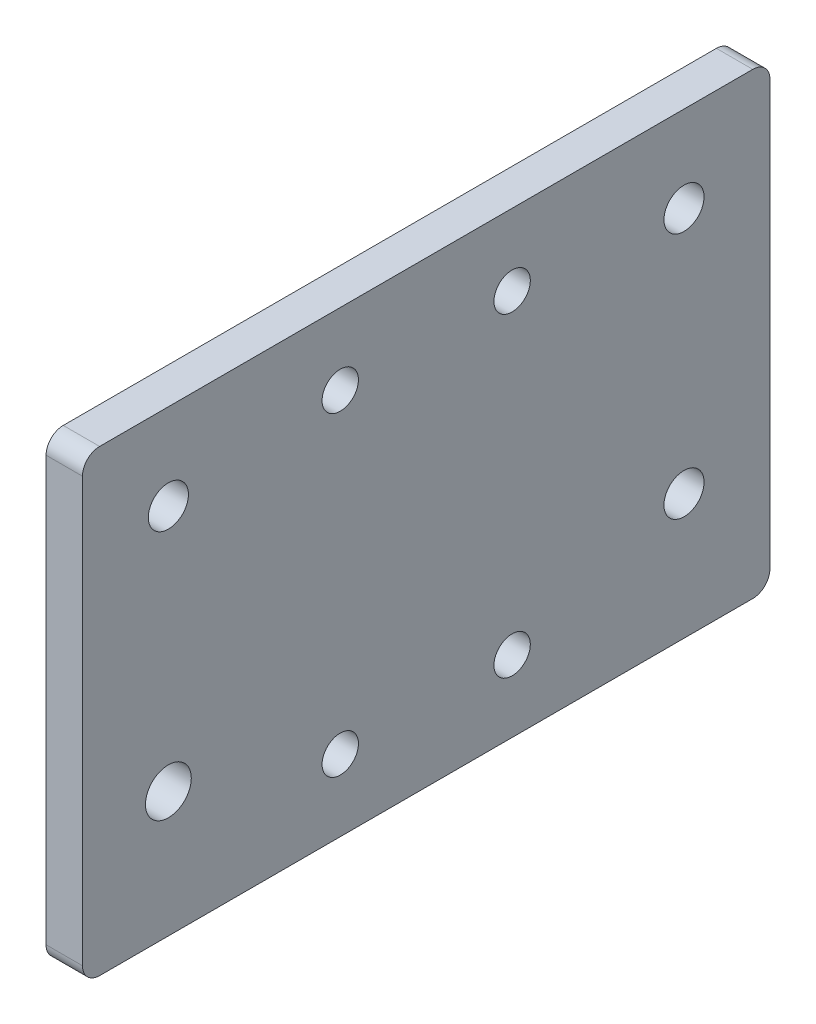
from build123d import *

# Parameters (mm, degrees)
SKETCH1_W           = 120
SKETCH1_H           = 80
SKETCH1_R           = 3.5
SKETCH1_R_2         = 4
BOSS_EXTRUDE1_DEPTH = 6.35
FILLET1_R           = 3
SKETCH2_R           = 3.175
CUT_EXTRUDE1_DEPTH  = 10


with BuildPart() as part:
    # Sketch1 → Boss-Extrude1 (new body)
    with BuildSketch(Plane(origin=(0, 0, 0), x_dir=(0, 0, -1), z_dir=(1, 0, 0))):
        Rectangle(SKETCH1_W, SKETCH1_H)
        with Locations((45, 25)):
            Circle(SKETCH1_R, mode=Mode.SUBTRACT)
        with Locations((-45, 25)):
            Circle(SKETCH1_R, mode=Mode.SUBTRACT)
        with Locations((-45, -18.13)):
            Circle(SKETCH1_R_2, mode=Mode.SUBTRACT)
        with Locations((45, -18.13)):
            Circle(SKETCH1_R, mode=Mode.SUBTRACT)
    extrude(amount=BOSS_EXTRUDE1_DEPTH)

    # Fillet1
    fillet1_edges = [part.edges().sort_by_distance(p)[0] for p in [
        (3.175, -40, -60),
        (3.175, -40, 60),
        (3.175, 40, 60),
        (3.175, 40, -60),
    ]]
    fillet(fillet1_edges, radius=FILLET1_R)

    # Sketch2 → Cut-Extrude1 (cut)
    with BuildSketch(Plane(origin=(6.35, 0, 0), x_dir=(0, 0, -1), z_dir=(1, 0, 0))):
        with Locations((-15, 27.5)):
            Circle(SKETCH2_R)
        with Locations((15, 27.5)):
            Circle(SKETCH2_R)
        with Locations((15, -27.5)):
            Circle(SKETCH2_R)
        with Locations((-15, -27.5)):
            Circle(SKETCH2_R)
    extrude(amount=-CUT_EXTRUDE1_DEPTH, mode=Mode.SUBTRACT)


solid = part.part
